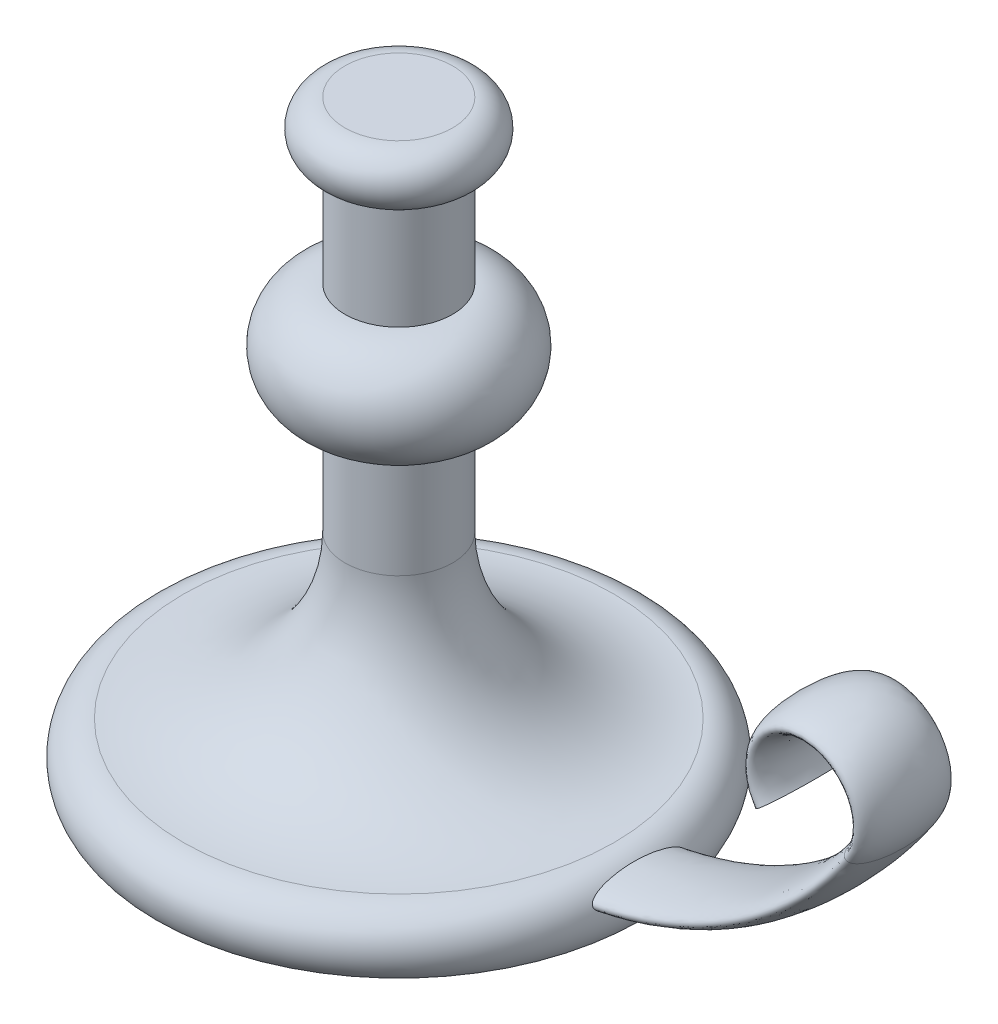
from build123d import *

# Parameters (mm, degrees)
SKETCH4_RX = 17.5
SKETCH4_RY = 5


with BuildPart() as part:
    # Sketch1 → Revolve1 (revolve)
    with BuildSketch(Plane.XY):
        with BuildLine():
            Line((0, 220), (0, 0))
            Line((0, 0), (90, 0))
            ThreePointArc((90, 0), (91.180339887, 13.090169944), (80, 20))
            ThreePointArc((80, 20), (37.573593129, 37.573593129), (20, 80))
            Line((20, 80), (20, 120))
            ThreePointArc((20, 120), (40, 140), (20, 160))
            Line((20, 160), (20, 200))
            ThreePointArc((20, 200), (30, 210), (20, 220))
            Line((20, 220), (0, 220))
        make_face()
    revolve(axis=Axis((0, 220, 0), (0, -1, 0)))

    # Sweep1: sweep along a path in Sketch2
    with BuildLine(Plane.XY) as sweep1_path:
        Line((0, 10), (60, 10))
        ThreePointArc((60, 10), (129.821200219, 27.240819526), (183.592070943, 75))
        ThreePointArc((183.592070943, 75), (167.113128151, 106.333333333), (150.634185358, 75))
    # Sketch4 → Sweep1 (sweep)
    with BuildSketch(Plane(origin=(0, 0, 0), x_dir=(0, 0, -1), z_dir=(1, 0, 0))):
        with Locations((0, 10)):
            Ellipse(SKETCH4_RX, SKETCH4_RY)
    sweep(path=sweep1_path.line)


solid = part.part
